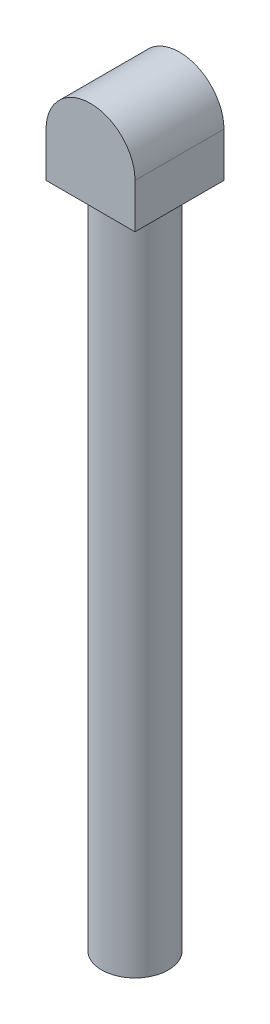
from build123d import *

# Parameters (mm, degrees)
SKETCH_1_W          = 8
SKETCH_1_H          = 8
EXTRUDE_1_DEPTH     = 8
CUT_EXTRUDE_1_DEPTH = 8
SKETCH_3_R          = 3
EXTRUDE_2_DEPTH     = 60


with BuildPart() as part:
    # 草图1 → 凸台-拉伸1 (new body)
    with BuildSketch(Plane(origin=(0, 0, 0), x_dir=(1, 0, 0), z_dir=(0, 1, 0))):
        Rectangle(SKETCH_1_W, SKETCH_1_H)
    extrude(amount=EXTRUDE_1_DEPTH)

    # 草图2 → 切除-拉伸1 (cut)
    with BuildSketch(Plane.XY.offset(4)):
        with BuildLine():
            Line((-4, 4), (-4, 9.423328326))
            Line((-4, 9.423328326), (4, 9.423328326))
            Line((4, 9.423328326), (4, 4))
            ThreePointArc((4, 4), (0, 8), (-4, 4))
        make_face()
    extrude(amount=-CUT_EXTRUDE_1_DEPTH, mode=Mode.SUBTRACT)

    # 草图3 → 凸台-拉伸2 (add)
    with BuildSketch(Plane.XZ):
        Circle(SKETCH_3_R)
    extrude(amount=EXTRUDE_2_DEPTH)


solid = part.part
